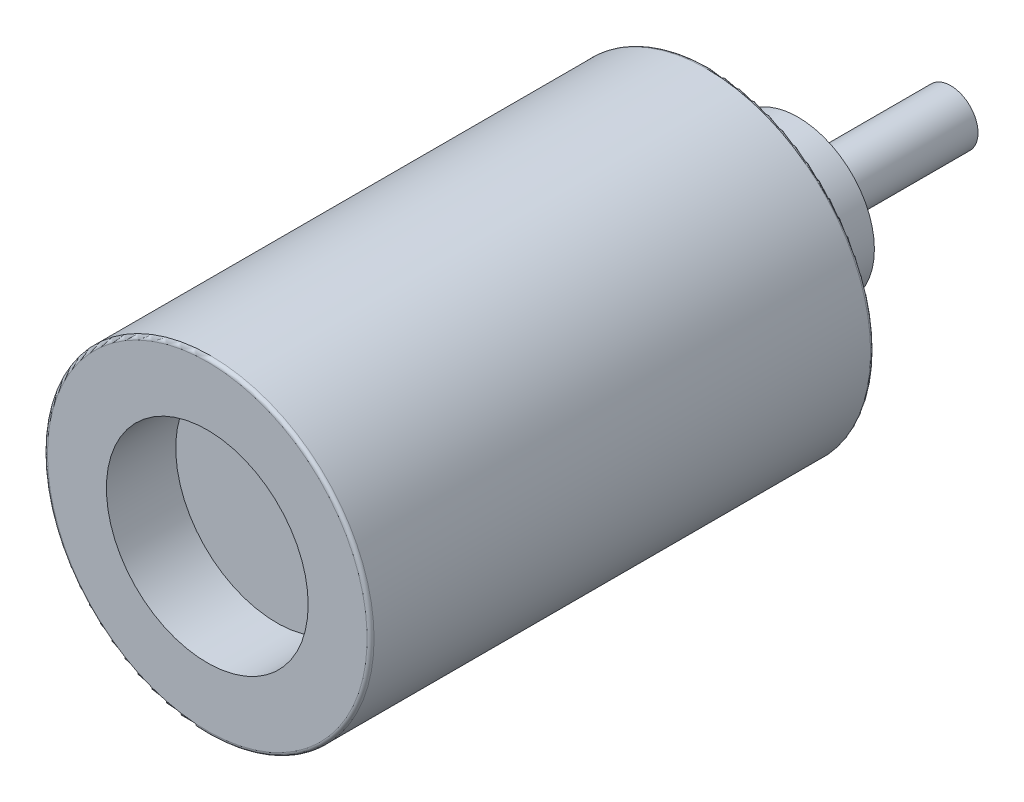
from build123d import *

# Parameters (mm, degrees)
FILLET1_R = 0.0635


with BuildPart() as part:
    # Sketch1 → Revolve1 (revolve)
    with BuildSketch(Plane(origin=(0, 0, 0), x_dir=(0, 0, -1), z_dir=(1, 0, 0))):
        Polygon((0, 2.99085), (9.2202, 2.99085), (9.2202, 1.397), (10.8204, 1.397), (10.8204, 0.5), (13.6144, 0.5), (13.6144, 0), (1.27, 0), (1.27, 1.84785), (0, 1.84785), align=None)
    revolve(axis=Axis((0, 0, 14.404430618), (0, 0, -1)))

    # Fillet1
    fillet1_edges = [part.edges().sort_by_distance(p)[0] for p in [
        (0, -2.99085, 0),
        (0, -2.99085, -9.2202),
    ]]
    fillet(fillet1_edges, radius=FILLET1_R)


solid = part.part
